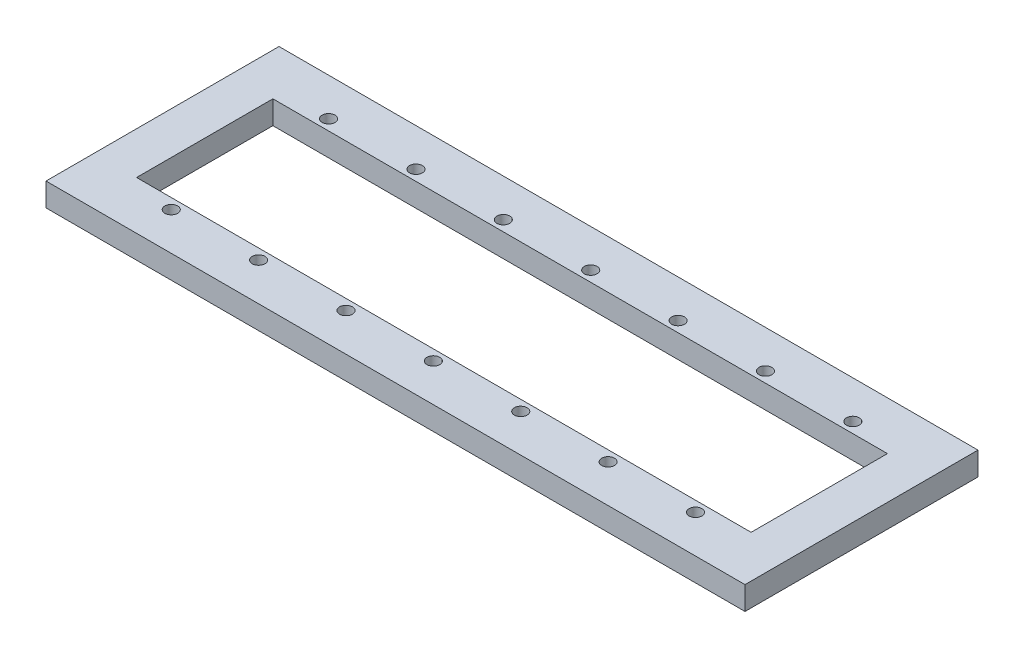
from build123d import *

# Parameters (mm, degrees)
SKETCH1_W           = 120
SKETCH1_H           = 40
BOSS_EXTRUDE1_DEPTH = 4
SKETCH2_R           = 1.1
SKETCH2_W           = 12.5
SKETCH2_H           = 23
CUT_EXTRUDE1_DEPTH  = 5
SKETCH3_W           = 105.5
SKETCH3_H           = 23.4
CUT_EXTRUDE2_DEPTH  = 5


with BuildPart() as part:
    # Sketch1 → Boss-Extrude1 (new body)
    with BuildSketch(Plane(origin=(0, 0, 0), x_dir=(1, 0, 0), z_dir=(0, 1, 0))):
        Rectangle(SKETCH1_W, SKETCH1_H)
    extrude(amount=BOSS_EXTRUDE1_DEPTH)

    # Sketch2 → Cut-Extrude1 (cut, through all)
    with BuildSketch(Plane(origin=(0, 4, 0), x_dir=(1, 0, 0), z_dir=(0, 1, 0))):
        with Locations((-44.998568235, 13.510712966)):
            Circle(SKETCH2_R)
        with Locations((-44.998568235, -13.5)):
            Circle(SKETCH2_R)
        with Locations((-29.998568235, 13.510712966)):
            Circle(SKETCH2_R)
        with Locations((-29.998568235, -13.5)):
            Circle(SKETCH2_R)
        with Locations((-14.998568235, 13.510712966)):
            Circle(SKETCH2_R)
        with Locations((-14.998568235, -13.5)):
            Circle(SKETCH2_R)
        with Locations((0.001431765, 13.510712966)):
            Circle(SKETCH2_R)
        with Locations((0.001431765, -13.5)):
            Circle(SKETCH2_R)
        with Locations((15.001431765, 13.510712966)):
            Circle(SKETCH2_R)
        with Locations((15.001431765, -13.5)):
            Circle(SKETCH2_R)
        with Locations((30.001431765, 13.510712966)):
            Circle(SKETCH2_R)
        with Locations((30.001431765, -13.5)):
            Circle(SKETCH2_R)
        with Locations((45.001431765, 13.510712966)):
            Circle(SKETCH2_R)
        with Locations((45.001431765, -13.5)):
            Circle(SKETCH2_R)
        with Locations((-29.998568235, 0)):
            Rectangle(SKETCH2_W, SKETCH2_H)
        with Locations((-44.998568235, 0)):
            Rectangle(SKETCH2_W, SKETCH2_H)
        with Locations((-14.998568235, 0)):
            Rectangle(SKETCH2_W, SKETCH2_H)
        with Locations((0.001431765, 0)):
            Rectangle(SKETCH2_W, SKETCH2_H)
        with Locations((15.001431765, 0)):
            Rectangle(SKETCH2_W, SKETCH2_H)
        with Locations((30.001431765, 0)):
            Rectangle(SKETCH2_W, SKETCH2_H)
        with Locations((45.001431765, 0)):
            Rectangle(SKETCH2_W, SKETCH2_H)
    extrude(amount=-CUT_EXTRUDE1_DEPTH, mode=Mode.SUBTRACT)

    # Sketch3 → Cut-Extrude2 (cut, through all)
    with BuildSketch(Plane(origin=(0, 4, 0), x_dir=(1, 0, 0), z_dir=(0, 1, 0))):
        with Locations((0.001431765, 0)):
            Rectangle(SKETCH3_W, SKETCH3_H)
    extrude(amount=-CUT_EXTRUDE2_DEPTH, mode=Mode.SUBTRACT)


solid = part.part
